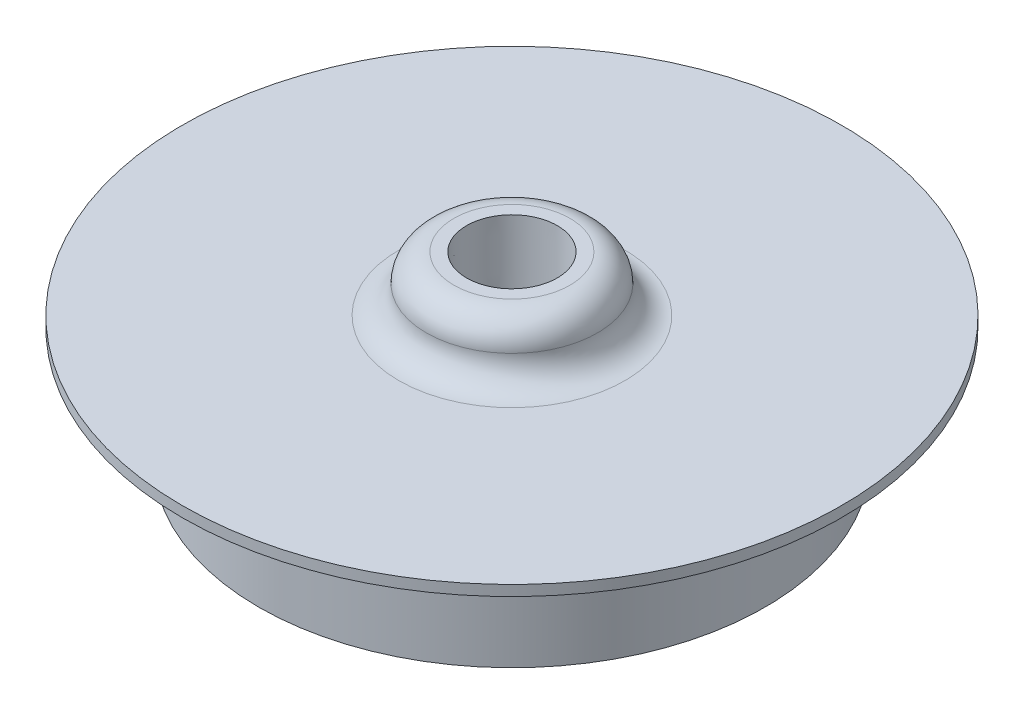
from build123d import *


with BuildPart() as part:
    # Sketch1 → Revolve1 (revolve)
    with BuildSketch(Plane.XY):
        with BuildLine():
            Line((-49.784, 0), (-39.839899999, 0))
            ThreePointArc((-39.839899999, 0), (-38.717367984, -0.464967985), (-38.252399999, -1.5875))
            Line((-38.252399999, -1.5875), (-38.2524, -17.4625))
            Line((-38.2524, -17.4625), (-35.0774, -17.4625))
            Line((-35.0774, -17.4625), (-35.0774, -3.175))
            ThreePointArc((-35.0774, -3.175), (-34.14746403, -0.92993597), (-31.9024, 0))
            Line((-31.9024, 0), (-5.588, 0))
            Line((-5.588, 0), (-5.588, 9.906))
            Line((-5.588, 9.906), (-8.763, 9.906))
            ThreePointArc((-8.763, 9.906), (-11.70403388, 8.68778388), (-12.92225, 5.74675))
            ThreePointArc((-12.92225, 5.74675), (-14.14046612, 2.80571612), (-17.0815, 1.5875))
            Line((-17.0815, 1.5875), (-49.784, 1.5875))
            Line((-49.784, 1.5875), (-49.784, 0))
        make_face()
    revolve(axis=Axis((0, 55, 0), (0, -1, 0)))

    # Sketch5 → 1/4 NPT Tapped Hole1 (revolve, cut)
    with BuildSketch(Plane(origin=(0, 9.906, 0), x_dir=(0, 0, 1), z_dir=(1, 0, 0))):
        Polygon((0, 0), (0, 27.3685), (5.5626, 27.3685), (5.5626, 9.906), (6.557984794, 9.906), (6.8545837, 0), align=None)
    revolve(axis=Axis((0, 16.256, 0), (0, -1, 0)), mode=Mode.SUBTRACT)


solid = part.part
